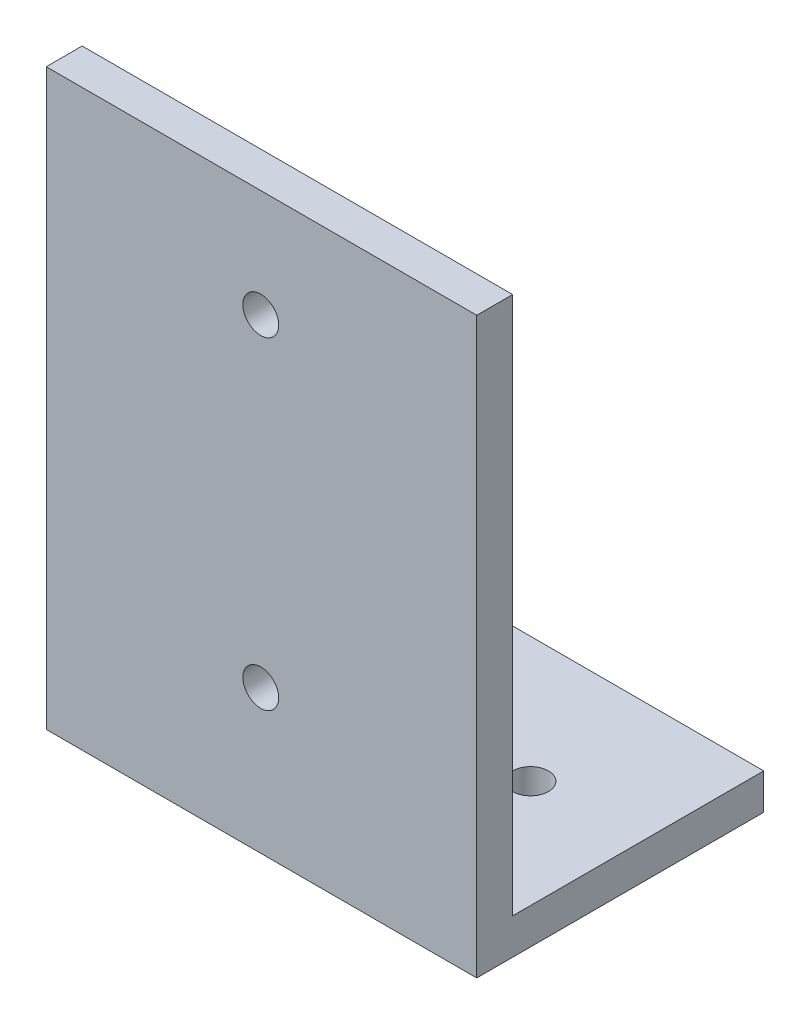
from build123d import *

# Parameters (mm, degrees)
BOSS_EXTRUDE1_DEPTH = 38.1
CUT_EXTRUDE1_REACH  = 5.175
SKETCH2_R           = 1.5875
CUT_EXTRUDE2_REACH  = 5.175
SKETCH3_R           = 1.5875


with BuildPart() as part:
    # Sketch1 → Boss-Extrude1 (new body)
    with BuildSketch(Plane(origin=(0, 0, 0), x_dir=(0, 0, -1), z_dir=(1, 0, 0))):
        Polygon((0, 0), (0, 50.8), (3.175, 50.8), (3.175, 3.175), (25.4, 3.175), (25.4, 0), align=None)
    extrude(amount=BOSS_EXTRUDE1_DEPTH)

    # Sketch2 → Cut-Extrude1 (cut, up to next)
    with BuildSketch(Plane(origin=(0, 3.175, 0), x_dir=(1, 0, 0), z_dir=(0, 1, 0)), mode=Mode.PRIVATE) as cut_extrude1_sk1:
        with Locations((28.575, 14.2875)):
            Circle(SKETCH2_R)
    cut_extrude1_tool1 = extrude(cut_extrude1_sk1.sketch, amount=-CUT_EXTRUDE1_REACH, mode=Mode.PRIVATE) & part.part
    add(cut_extrude1_tool1.solids().sort_by_distance((28.575, 3.175, -14.2875))[0], mode=Mode.SUBTRACT)
    # Sketch2 → Cut-Extrude1 (cut, up to next)
    with BuildSketch(Plane(origin=(0, 3.175, 0), x_dir=(1, 0, 0), z_dir=(0, 1, 0)), mode=Mode.PRIVATE) as cut_extrude1_sk2:
        with Locations((9.525, 14.2875)):
            Circle(SKETCH2_R)
    cut_extrude1_tool2 = extrude(cut_extrude1_sk2.sketch, amount=-CUT_EXTRUDE1_REACH, mode=Mode.PRIVATE) & part.part
    add(cut_extrude1_tool2.solids().sort_by_distance((9.525, 3.175, -14.2875))[0], mode=Mode.SUBTRACT)

    # Sketch3 → Cut-Extrude2 (cut, up to next)
    with BuildSketch(Plane(origin=(0, 0, -3.175), x_dir=(-1, 0, 0), z_dir=(0, 0, -1)), mode=Mode.PRIVATE) as cut_extrude2_sk1:
        with Locations((-18.983298196, 12.7)):
            Circle(SKETCH3_R)
    cut_extrude2_tool1 = extrude(cut_extrude2_sk1.sketch, amount=-CUT_EXTRUDE2_REACH, mode=Mode.PRIVATE) & part.part
    add(cut_extrude2_tool1.solids().sort_by_distance((18.983298, 12.7, -3.175))[0], mode=Mode.SUBTRACT)
    # Sketch3 → Cut-Extrude2 (cut, up to next)
    with BuildSketch(Plane(origin=(0, 0, -3.175), x_dir=(-1, 0, 0), z_dir=(0, 0, -1)), mode=Mode.PRIVATE) as cut_extrude2_sk2:
        with Locations((-18.983298196, 41.275)):
            Circle(SKETCH3_R)
    cut_extrude2_tool2 = extrude(cut_extrude2_sk2.sketch, amount=-CUT_EXTRUDE2_REACH, mode=Mode.PRIVATE) & part.part
    add(cut_extrude2_tool2.solids().sort_by_distance((18.983298, 41.275, -3.175))[0], mode=Mode.SUBTRACT)


solid = part.part
